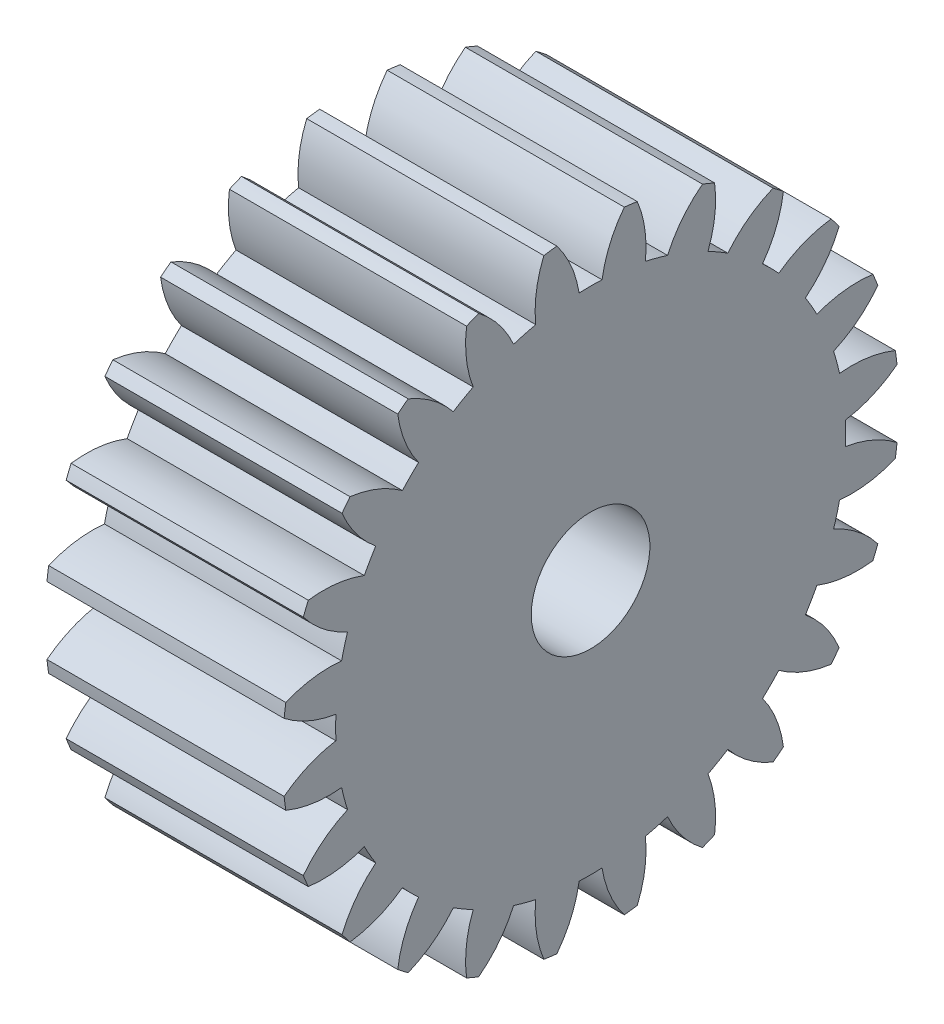
from build123d import *

# Parameters (mm, degrees)
BASPROSKE_W     = 10
BASPROSKE_H     = 13
TOOTHCUT_DEPTH  = 21.928449536
TEETHCUTS_COUNT = 24
TEETHCUTS_ANGLE = 345
BORSKE_R        = 2.5
BORE_DEPTH      = 50.0000508


with BuildPart() as part:
    # BasProSke → Base-Revolve (revolve)
    with BuildSketch(Plane(origin=(0, 0, 0), x_dir=(1, 0, 0), z_dir=(0, 1, 0)), mode=Mode.PRIVATE) as base_revolve_sk:
        with Locations((5, 6.5)):
            Rectangle(BASPROSKE_W, BASPROSKE_H)
    revolve(base_revolve_sk.sketch.rotate(Axis((-10, 0, 0), (1, 0, 0)), 180), axis=Axis((-10, 0, 0), (1, 0, 0)))

    # TooCutSke → ToothCut (cut, through all)
    with BuildSketch(Plane(origin=(0, 0, 0), x_dir=(0, 0, -1), z_dir=(1, 0, 0))):
        with BuildLine():
            ThreePointArc((0.483448384, 10.738122679), (0, 10.749), (-0.483448384, 10.738122679))
            ThreePointArc((-0.483448384, 10.738122679), (-0.821636462, 11.902754369), (-1.44092227, 12.945454344))
            ThreePointArc((-1.44092227, 12.945454344), (0, 13.0254), (1.44092227, 12.945454344))
            ThreePointArc((1.44092227, 12.945454344), (0.821636462, 11.902754369), (0.483448384, 10.738122679))
        make_face()
    toothcut = extrude(amount=TOOTHCUT_DEPTH, mode=Mode.SUBTRACT)

    # TeethCuts: ToothCut ×24 about axis
    teethcuts_axis = Axis((-10, 0, 0), (1, 0, 0))
    for i in range(1, TEETHCUTS_COUNT):
        add(toothcut.rotate(teethcuts_axis, i * TEETHCUTS_ANGLE / (TEETHCUTS_COUNT - 1)), mode=Mode.SUBTRACT)

    # BorSke → Bore (cut, symmetric)
    with BuildSketch(Plane(origin=(0, 0, 0), x_dir=(0, 0, -1), z_dir=(1, 0, 0))):
        with Locations(Location((0, 0, 0), (0, 0, 180))):
            Circle(BORSKE_R)
    extrude(amount=BORE_DEPTH, both=True, mode=Mode.SUBTRACT)


solid = part.part
